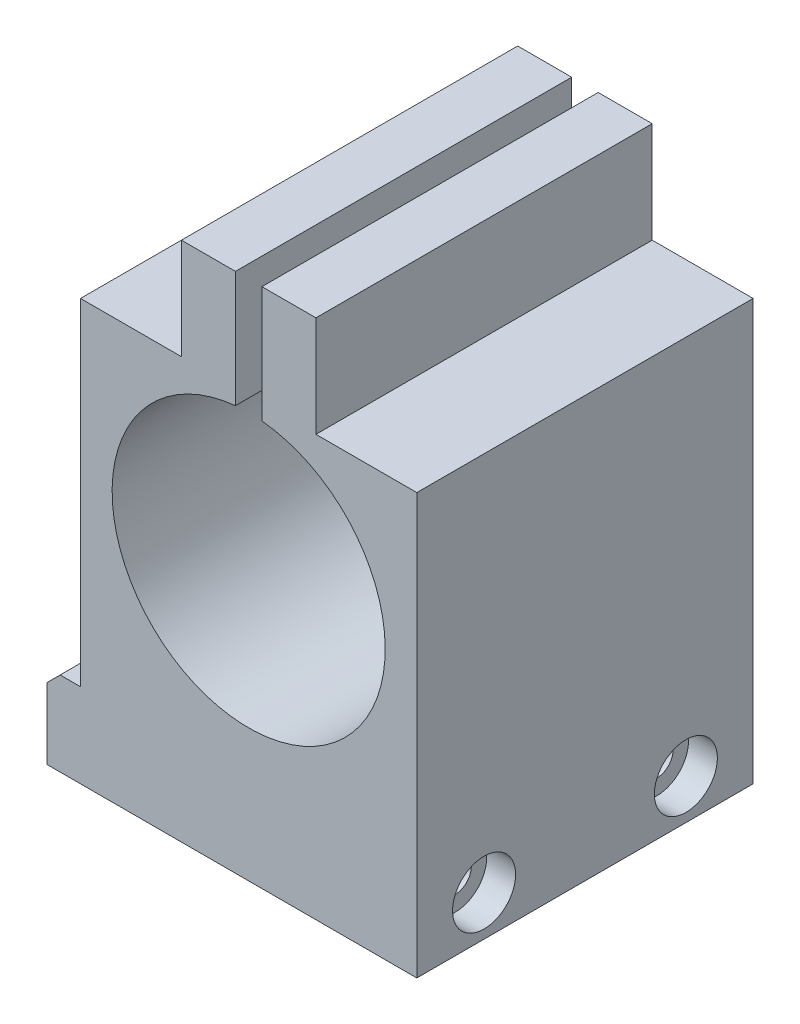
from build123d import *

# Parameters (mm, degrees)
BOSS_EXTRUDE1_DEPTH                            = 25.4
CHAMFER1_SIZE                                  = 1
CBORE_FOR_2_SOCKET_HEAD_CAP_SCREW1_D           = 2.4384
CBORE_FOR_2_SOCKET_HEAD_CAP_SCREW1_CBORE_D     = 4.7625
CBORE_FOR_2_SOCKET_HEAD_CAP_SCREW1_CBORE_DEPTH = 2.1844


with BuildPart() as part:
    # Sketch1 → Boss-Extrude1 (new body)
    with BuildSketch(Plane.XY):
        with BuildLine():
            Line((0.109825555, 12.7), (0.109825555, 6.35))
            Line((0.109825555, 6.35), (28.049825555, 6.35))
            Line((28.049825555, 6.35), (28.049825555, 38.1))
            Line((28.049825555, 38.1), (20.429825555, 38.1))
            Line((20.429825555, 38.1), (20.429825555, 45.72))
            Line((20.429825555, 45.72), (16.349825555, 45.72))
            Line((16.349825555, 45.72), (16.349825555, 36.933800162))
            ThreePointArc((16.349825555, 36.933800162), (15.349825555, 16.3576), (14.349825555, 36.933800162))
            Line((14.349825555, 36.933800162), (14.349825555, 45.72))
            Line((14.349825555, 45.72), (10.269825555, 45.72))
            Line((10.269825555, 45.72), (10.269825555, 38.1))
            Line((10.269825555, 38.1), (2.649825555, 38.1))
            Line((2.649825555, 38.1), (2.649825555, 12.7))
            Line((2.649825555, 12.7), (0.109825555, 12.7))
        make_face()
    extrude(amount=BOSS_EXTRUDE1_DEPTH)

    # Chamfer1
    chamfer1_edges = [part.edges().sort_by_distance(p)[0] for p in [
        (0.109825555, 12.7, 12.7),
    ]]
    chamfer(chamfer1_edges, length=CHAMFER1_SIZE)

    # CBORE for #2 Socket Head Cap Screw1 (through all)
    with Locations(Plane(origin=(28.049825555, 0, 0), x_dir=(0, 0, -1), z_dir=(1, 0, 0))):
        with Locations((-20.32, 9.398), (-5.08, 9.398)):
            CounterBoreHole(CBORE_FOR_2_SOCKET_HEAD_CAP_SCREW1_D / 2, CBORE_FOR_2_SOCKET_HEAD_CAP_SCREW1_CBORE_D / 2, CBORE_FOR_2_SOCKET_HEAD_CAP_SCREW1_CBORE_DEPTH)


solid = part.part
